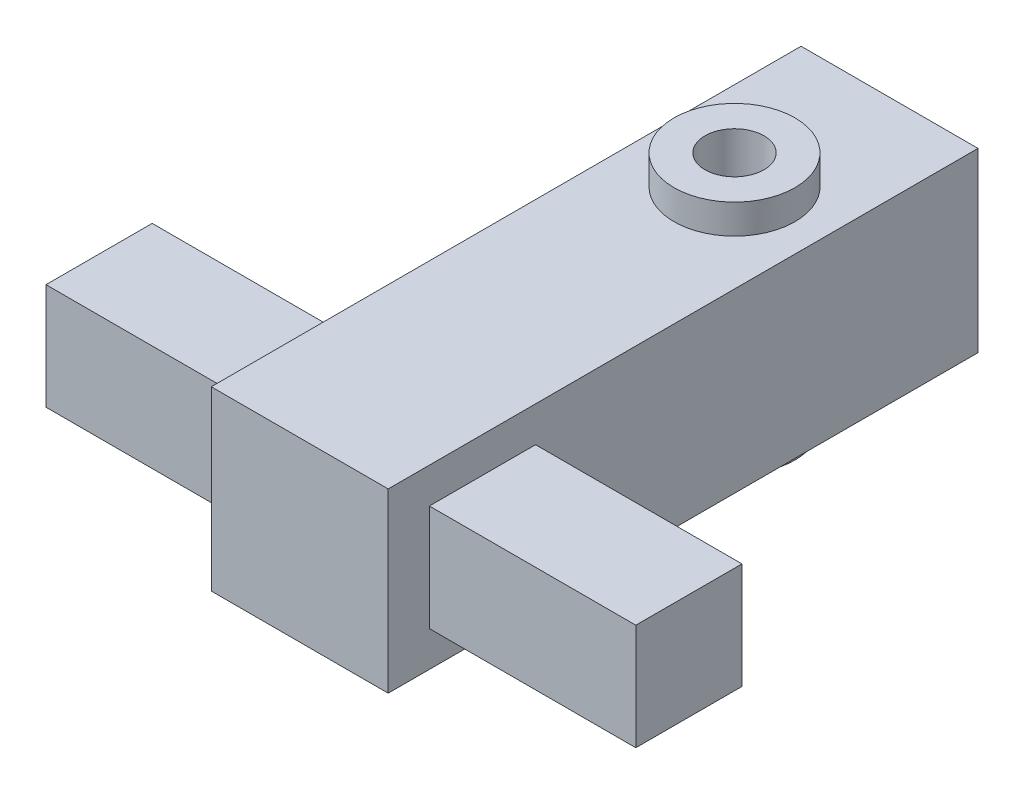
from build123d import *

# Parameters (mm, degrees)
SKETCH_2_W               = 30
SKETCH_2_H               = 30
EXTRUDE_1_DEPTH          = 100
SKETCH_3_W               = 18
SKETCH_3_H               = 18
EXTRUDE_2_DEPTH          = 35
PATTERN_CIRCULAR_1_COUNT = 2
SKETCH_4_R               = 10.254249717
EXTRUDE_4_DEPTH          = 5
SKETCH_5_R               = 5
CUT_EXTRUDE_2_DEPTH      = 15
PATTERN_CIRCULAR_3_COUNT = 2
PATTERN_CIRCULAR_4_COUNT = 2


with BuildPart() as part:
    # 草图2 → 凸台-拉伸1 (new body)
    with BuildSketch(Plane.XY):
        Rectangle(SKETCH_2_W, SKETCH_2_H)
    extrude(amount=EXTRUDE_1_DEPTH)

    # 草图3 → 凸台-拉伸2 (add)
    with BuildSketch(Plane(origin=(15, 0, 0), x_dir=(0, 0, -1), z_dir=(1, 0, 0))):
        with Locations((-84.019000904, 0)):
            Rectangle(SKETCH_3_W, SKETCH_3_H)
    extrude_2 = extrude(amount=EXTRUDE_2_DEPTH)

    # 阵列(圆周)1: 凸台-拉伸2 ×2 about axis
    pattern_circular_1_axis = Axis((0, 0, 0), (0, 0, 1))
    for i in range(1, PATTERN_CIRCULAR_1_COUNT):
        add(extrude_2.rotate(pattern_circular_1_axis, i * 360 / PATTERN_CIRCULAR_1_COUNT))

    # 草图4 → 凸台-拉伸4 (add)
    with BuildSketch(Plane(origin=(0, 15, 0), x_dir=(1, 0, 0), z_dir=(0, 1, 0))):
        with Locations((0, -26.28538531)):
            Circle(SKETCH_4_R)
    extrude_4 = extrude(amount=EXTRUDE_4_DEPTH)

    # 草图5 → 切除-拉伸2 (cut)
    with BuildSketch(Plane(origin=(0, 20, 0), x_dir=(1, 0, 0), z_dir=(0, 1, 0))):
        with Locations((0, -26.28538531)):
            Circle(SKETCH_5_R)
    cut_extrude_2 = extrude(amount=-CUT_EXTRUDE_2_DEPTH, mode=Mode.SUBTRACT)

    # 阵列(圆周)3: 凸台-拉伸4 ×2 about axis
    pattern_circular_3_axis = Axis((0, 0, 100), (0, 0, -1))
    for i in range(1, PATTERN_CIRCULAR_3_COUNT):
        add(extrude_4.rotate(pattern_circular_3_axis, i * 360 / PATTERN_CIRCULAR_3_COUNT))

    # 阵列(圆周)4: 切除-拉伸2 ×2 about axis
    pattern_circular_4_axis = Axis((0, 0, 100), (0, 0, -1))
    for i in range(1, PATTERN_CIRCULAR_4_COUNT):
        add(cut_extrude_2.rotate(pattern_circular_4_axis, i * 360 / PATTERN_CIRCULAR_4_COUNT), mode=Mode.SUBTRACT)


solid = part.part
